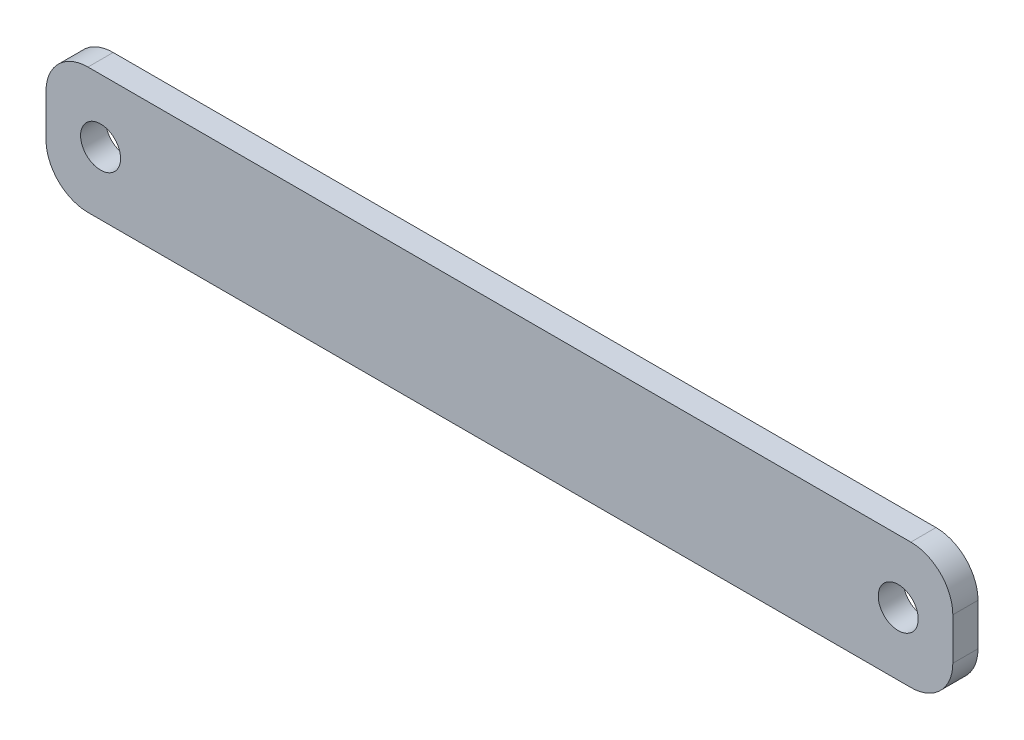
from build123d import *

# Parameters (mm, degrees)
CROQUIS1_R              = 2.38125
SALIENTE_EXTRUIR1_DEPTH = 3


with BuildPart() as part:
    # Croquis1 → Saliente-Extruir1 (new body)
    with BuildSketch(Plane.XY):
        with BuildLine():
            Line((5, 0), (103, 0))
            ThreePointArc((103, 0), (106.535533906, 1.464466094), (108, 5))
            Line((108, 5), (108, 10))
            ThreePointArc((108, 10), (106.535533906, 13.535533906), (103, 15))
            Line((103, 15), (5, 15))
            ThreePointArc((5, 15), (1.464466094, 13.535533906), (0, 10))
            Line((0, 10), (0, 5))
            ThreePointArc((0, 5), (1.464466094, 1.464466094), (5, 0))
        make_face()
        with Locations((101.5, 7.5)):
            Circle(CROQUIS1_R, mode=Mode.SUBTRACT)
        with Locations((6.5, 7.5)):
            Circle(CROQUIS1_R, mode=Mode.SUBTRACT)
    extrude(amount=SALIENTE_EXTRUIR1_DEPTH)


solid = part.part
